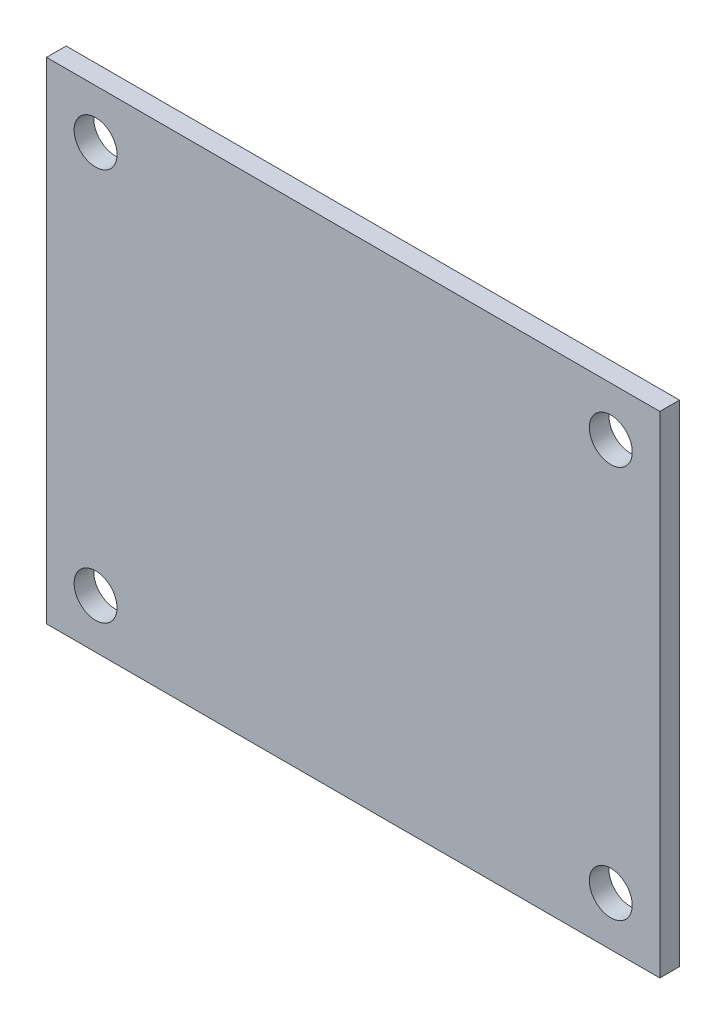
from build123d import *

# Parameters (mm, degrees)
MODEL_W            = 50.0000016
MODEL_H            = 39.9999962
MODEL_R            = 1.7500092
BOSS_EXTRU_1_DEPTH = 1.6


with BuildPart() as part:
    # Model → Boss.-Extru.1 (new body)
    with BuildSketch(Plane.XY):
        with Locations((25.0000008, 19.9999981)):
            Rectangle(MODEL_W, MODEL_H)
        with Locations((4, 4)):
            Circle(MODEL_R, mode=Mode.SUBTRACT)
        with Locations((46.0000096, 3.999992)):
            Circle(MODEL_R, mode=Mode.SUBTRACT)
        with Locations((46.0000096, 36.0000042)):
            Circle(MODEL_R, mode=Mode.SUBTRACT)
        with Locations((3.999992, 36.0000042)):
            Circle(MODEL_R, mode=Mode.SUBTRACT)
    extrude(amount=BOSS_EXTRU_1_DEPTH)


solid = part.part
